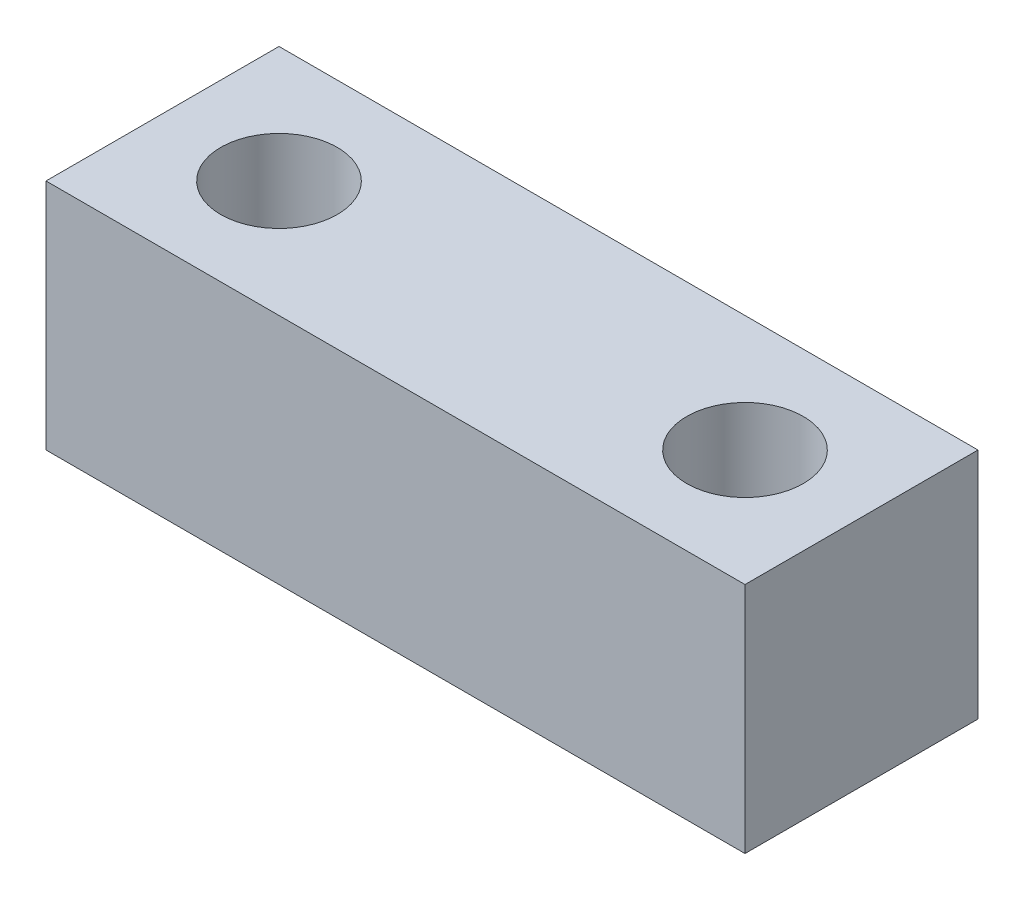
from build123d import *

# Parameters (mm, degrees)
SKETCH1_W           = 76.2
SKETCH1_H           = 25.4
SKETCH1_R           = 6.35
BOSS_EXTRUDE1_DEPTH = 25.4


with BuildPart() as part:
    # Sketch1 → Boss-Extrude1 (new body)
    with BuildSketch(Plane(origin=(0, 0, 0), x_dir=(1, 0, 0), z_dir=(0, 1, 0))):
        with Locations((-38.1, 12.7)):
            Rectangle(SKETCH1_W, SKETCH1_H)
        with Locations((-63.5, 12.7)):
            Circle(SKETCH1_R, mode=Mode.SUBTRACT)
        with Locations((-12.7, 12.7)):
            Circle(SKETCH1_R, mode=Mode.SUBTRACT)
    extrude(amount=BOSS_EXTRUDE1_DEPTH)


solid = part.part
